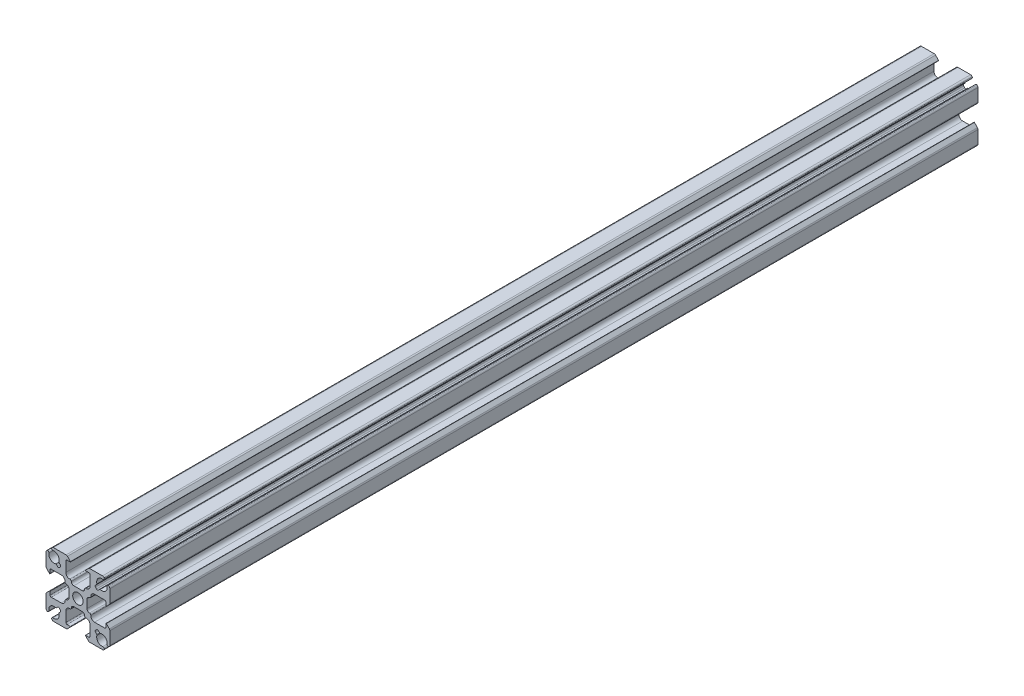
from build123d import *

# Parameters (mm, degrees)
SKETCH1_R                            = 2.08
BOSS_EXTRUDE1_DEPTH                  = 172.5549
SKETCH2_W                            = 2.5
SKETCH2_H                            = 16.3
TAP_DRILL_FOR_M6X1_0_TAP2_AT_2_COUNT = 2
TAP_DRILL_FOR_M6X1_0_TAP2_AT_2_PITCH = 135.89
SKETCH4_W                            = 2.5
SKETCH4_H                            = 16.3
TAP_DRILL_FOR_M6X1_0_TAP1_AT_2_COUNT = 2
TAP_DRILL_FOR_M6X1_0_TAP1_AT_2_PITCH = 120
TAP_DRILL_FOR_M6X1_0_TAP1_AT_3_COUNT = 2
TAP_DRILL_FOR_M6X1_0_TAP1_AT_3_PITCH = 240


with BuildPart() as part:
    # Sketch1 → Boss-Extrude1 (new body, symmetric)
    with BuildSketch(Plane(origin=(0, 0, 0), x_dir=(-1, 0, 0), z_dir=(0, 0, -1))):
        with BuildLine():
            Line((-7.48853247, 8.61990332), (-6.985643798, 8.117014648))
            ThreePointArc((-6.985643798, 8.117014648), (-6.839197188, 7.763461257), (-6.985643798, 7.409907866))
            Line((-6.985643798, 7.409907866), (-7.409907866, 6.985643798))
            ThreePointArc((-7.409907866, 6.985643798), (-7.763461257, 6.839197188), (-8.117014648, 6.985643798))
            Line((-8.117014648, 6.985643798), (-8.61990332, 7.48853247))
            ThreePointArc((-8.61990332, 7.48853247), (-8.738774884, 7.554957329), (-8.874825936, 7.549228331))
            ThreePointArc((-8.874825936, 7.549228331), (-10.889377278, 7.955008076), (-11.572136222, 9.893284252))
            ThreePointArc((-11.572136222, 9.893284252), (-11.766795458, 10.383720777), (-12.292708824, 10.42656157))
            ThreePointArc((-12.292708824, 10.42656157), (-12.590129525, 10.150252615), (-12.7, 9.759440396))
            Line((-12.7, 9.759440396), (-12.7, 4.710660172))
            ThreePointArc((-12.7, 4.710660172), (-12.642909649, 4.423647598), (-12.480330086, 4.180330086))
            Line((-12.480330086, 4.180330086), (-11.270710678, 2.970710678))
            ThreePointArc((-11.270710678, 2.970710678), (-11.161731657, 2.949033403), (-11.1, 3.041421356))
            Line((-11.1, 3.041421356), (-11.1, 4.325))
            ThreePointArc((-11.1, 4.325), (-10.953553391, 4.678553391), (-10.6, 4.825))
            Line((-10.6, 4.825), (-6.6, 4.825))
            ThreePointArc((-6.6, 4.825), (-5.539339828, 4.385660172), (-5.1, 3.325))
            Line((-5.1, 3.325), (-5.1, 3.15))
            ThreePointArc((-5.1, 3.15), (-4.953553391, 2.796446609), (-4.6, 2.65))
            ThreePointArc((-4.6, 2.65), (-3.892893219, 2.357106781), (-3.6, 1.65))
            Line((-3.6, 1.65), (-3.6, -1.65))
            ThreePointArc((-3.6, -1.65), (-3.892893219, -2.357106781), (-4.6, -2.65))
            ThreePointArc((-4.6, -2.65), (-4.953553391, -2.796446609), (-5.1, -3.15))
            Line((-5.1, -3.15), (-5.1, -3.325))
            ThreePointArc((-5.1, -3.325), (-5.539339828, -4.385660172), (-6.6, -4.825))
            Line((-6.6, -4.825), (-10.6, -4.825))
            ThreePointArc((-10.6, -4.825), (-10.953553391, -4.678553391), (-11.1, -4.325))
            Line((-11.1, -4.325), (-11.1, -3.041421356))
            ThreePointArc((-11.1, -3.041421356), (-11.161731657, -2.949033403), (-11.270710678, -2.970710678))
            Line((-11.270710678, -2.970710678), (-12.480330086, -4.180330086))
            ThreePointArc((-12.480330086, -4.180330086), (-12.642909649, -4.423647598), (-12.7, -4.710660172))
            Line((-12.7, -4.710660172), (-12.7, -9.759440396))
            ThreePointArc((-12.7, -9.759440396), (-12.590129525, -10.150252615), (-12.292708824, -10.42656157))
            ThreePointArc((-12.292708824, -10.42656157), (-11.766795458, -10.383720777), (-11.572136222, -9.893284252))
            ThreePointArc((-11.572136222, -9.893284252), (-10.889377278, -7.955008076), (-8.874825936, -7.549228331))
            ThreePointArc((-8.874825936, -7.549228331), (-8.738774884, -7.554957329), (-8.61990332, -7.48853247))
            Line((-8.61990332, -7.48853247), (-8.117014648, -6.985643798))
            ThreePointArc((-8.117014648, -6.985643798), (-7.763461257, -6.839197188), (-7.409907866, -6.985643798))
            Line((-7.409907866, -6.985643798), (-6.985643798, -7.409907866))
            ThreePointArc((-6.985643798, -7.409907866), (-6.839197188, -7.763461257), (-6.985643798, -8.117014648))
            Line((-6.985643798, -8.117014648), (-7.48853247, -8.61990332))
            ThreePointArc((-7.48853247, -8.61990332), (-7.554957329, -8.738774884), (-7.549228331, -8.874825936))
            ThreePointArc((-7.549228331, -8.874825936), (-7.955008076, -10.889377278), (-9.893284252, -11.572136222))
            ThreePointArc((-9.893284252, -11.572136222), (-10.383720777, -11.766795458), (-10.42656157, -12.292708824))
            ThreePointArc((-10.42656157, -12.292708824), (-10.150252615, -12.590129525), (-9.759440396, -12.7))
            Line((-9.759440396, -12.7), (-4.710660172, -12.7))
            ThreePointArc((-4.710660172, -12.7), (-4.423647598, -12.642909649), (-4.180330086, -12.480330086))
            Line((-4.180330086, -12.480330086), (-2.970710678, -11.270710678))
            ThreePointArc((-2.970710678, -11.270710678), (-2.949033403, -11.161731657), (-3.041421356, -11.1))
            Line((-3.041421356, -11.1), (-4.325, -11.1))
            ThreePointArc((-4.325, -11.1), (-4.678553391, -10.953553391), (-4.825, -10.6))
            Line((-4.825, -10.6), (-4.825, -6.6))
            ThreePointArc((-4.825, -6.6), (-4.385660172, -5.539339828), (-3.325, -5.1))
            Line((-3.325, -5.1), (-3.15, -5.1))
            ThreePointArc((-3.15, -5.1), (-2.796446609, -4.953553391), (-2.65, -4.6))
            ThreePointArc((-2.65, -4.6), (-2.357106781, -3.892893219), (-1.65, -3.6))
            Line((-1.65, -3.6), (1.65, -3.6))
            ThreePointArc((1.65, -3.6), (2.357106781, -3.892893219), (2.65, -4.6))
            ThreePointArc((2.65, -4.6), (2.796446609, -4.953553391), (3.15, -5.1))
            Line((3.15, -5.1), (3.325, -5.1))
            ThreePointArc((3.325, -5.1), (4.385660172, -5.539339828), (4.825, -6.6))
            Line((4.825, -6.6), (4.825, -10.6))
            ThreePointArc((4.825, -10.6), (4.678553391, -10.953553391), (4.325, -11.1))
            Line((4.325, -11.1), (3.041421356, -11.1))
            ThreePointArc((3.041421356, -11.1), (2.949033403, -11.161731657), (2.970710678, -11.270710678))
            Line((2.970710678, -11.270710678), (4.180330086, -12.480330086))
            ThreePointArc((4.180330086, -12.480330086), (4.423647598, -12.642909649), (4.710660172, -12.7))
            Line((4.710660172, -12.7), (9.759440396, -12.7))
            ThreePointArc((9.759440396, -12.7), (10.150252615, -12.590129525), (10.42656157, -12.292708824))
            ThreePointArc((10.42656157, -12.292708824), (10.383720777, -11.766795458), (9.893284252, -11.572136222))
            ThreePointArc((9.893284252, -11.572136222), (7.955008076, -10.889377278), (7.549228331, -8.874825936))
            ThreePointArc((7.549228331, -8.874825936), (7.554957329, -8.738774884), (7.48853247, -8.61990332))
            Line((7.48853247, -8.61990332), (6.985643798, -8.117014648))
            ThreePointArc((6.985643798, -8.117014648), (6.839197188, -7.763461257), (6.985643798, -7.409907866))
            Line((6.985643798, -7.409907866), (7.409907866, -6.985643798))
            ThreePointArc((7.409907866, -6.985643798), (7.763461257, -6.839197188), (8.117014648, -6.985643798))
            Line((8.117014648, -6.985643798), (8.61990332, -7.48853247))
            ThreePointArc((8.61990332, -7.48853247), (8.738774884, -7.554957329), (8.874825936, -7.549228331))
            ThreePointArc((8.874825936, -7.549228331), (10.889377278, -7.955008076), (11.572136222, -9.893284252))
            ThreePointArc((11.572136222, -9.893284252), (11.766795458, -10.383720777), (12.292708824, -10.42656157))
            ThreePointArc((12.292708824, -10.42656157), (12.590129525, -10.150252615), (12.7, -9.759440396))
            Line((12.7, -9.759440396), (12.7, -4.710660172))
            ThreePointArc((12.7, -4.710660172), (12.642909649, -4.423647598), (12.480330086, -4.180330086))
            Line((12.480330086, -4.180330086), (11.270710678, -2.970710678))
            ThreePointArc((11.270710678, -2.970710678), (11.161731657, -2.949033403), (11.1, -3.041421356))
            Line((11.1, -3.041421356), (11.1, -4.325))
            ThreePointArc((11.1, -4.325), (10.953553391, -4.678553391), (10.6, -4.825))
            Line((10.6, -4.825), (6.6, -4.825))
            ThreePointArc((6.6, -4.825), (5.539339828, -4.385660172), (5.1, -3.325))
            Line((5.1, -3.325), (5.1, -3.15))
            ThreePointArc((5.1, -3.15), (4.953553391, -2.796446609), (4.6, -2.65))
            ThreePointArc((4.6, -2.65), (3.892893219, -2.357106781), (3.6, -1.65))
            Line((3.6, -1.65), (3.6, 1.65))
            ThreePointArc((3.6, 1.65), (3.892893219, 2.357106781), (4.6, 2.65))
            ThreePointArc((4.6, 2.65), (4.953553391, 2.796446609), (5.1, 3.15))
            Line((5.1, 3.15), (5.1, 3.325))
            ThreePointArc((5.1, 3.325), (5.539339828, 4.385660172), (6.6, 4.825))
            Line((6.6, 4.825), (10.6, 4.825))
            ThreePointArc((10.6, 4.825), (10.953553391, 4.678553391), (11.1, 4.325))
            Line((11.1, 4.325), (11.1, 3.041421356))
            ThreePointArc((11.1, 3.041421356), (11.161731657, 2.949033403), (11.270710678, 2.970710678))
            Line((11.270710678, 2.970710678), (12.480330086, 4.180330086))
            ThreePointArc((12.480330086, 4.180330086), (12.642909649, 4.423647598), (12.7, 4.710660172))
            Line((12.7, 4.710660172), (12.7, 9.759440396))
            ThreePointArc((12.7, 9.759440396), (12.590129525, 10.150252615), (12.292708824, 10.42656157))
            ThreePointArc((12.292708824, 10.42656157), (11.766795458, 10.383720777), (11.572136222, 9.893284252))
            ThreePointArc((11.572136222, 9.893284252), (10.889377278, 7.955008076), (8.874825936, 7.549228331))
            ThreePointArc((8.874825936, 7.549228331), (8.738774884, 7.554957329), (8.61990332, 7.48853247))
            Line((8.61990332, 7.48853247), (8.117014648, 6.985643798))
            ThreePointArc((8.117014648, 6.985643798), (7.763461257, 6.839197188), (7.409907866, 6.985643798))
            Line((7.409907866, 6.985643798), (6.985643798, 7.409907866))
            ThreePointArc((6.985643798, 7.409907866), (6.839197188, 7.763461257), (6.985643798, 8.117014648))
            Line((6.985643798, 8.117014648), (7.48853247, 8.61990332))
            ThreePointArc((7.48853247, 8.61990332), (7.554957329, 8.738774884), (7.549228331, 8.874825936))
            ThreePointArc((7.549228331, 8.874825936), (7.955008076, 10.889377278), (9.893284252, 11.572136222))
            ThreePointArc((9.893284252, 11.572136222), (10.383720777, 11.766795458), (10.42656157, 12.292708824))
            ThreePointArc((10.42656157, 12.292708824), (10.150252615, 12.590129525), (9.759440396, 12.7))
            Line((9.759440396, 12.7), (4.710660172, 12.7))
            ThreePointArc((4.710660172, 12.7), (4.423647598, 12.642909649), (4.180330086, 12.480330086))
            Line((4.180330086, 12.480330086), (2.970710678, 11.270710678))
            ThreePointArc((2.970710678, 11.270710678), (2.949033403, 11.161731657), (3.041421356, 11.1))
            Line((3.041421356, 11.1), (4.325, 11.1))
            ThreePointArc((4.325, 11.1), (4.678553391, 10.953553391), (4.825, 10.6))
            Line((4.825, 10.6), (4.825, 6.6))
            ThreePointArc((4.825, 6.6), (4.385660172, 5.539339828), (3.325, 5.1))
            Line((3.325, 5.1), (3.15, 5.1))
            ThreePointArc((3.15, 5.1), (2.796446609, 4.953553391), (2.65, 4.6))
            ThreePointArc((2.65, 4.6), (2.357106781, 3.892893219), (1.65, 3.6))
            Line((1.65, 3.6), (-1.65, 3.6))
            ThreePointArc((-1.65, 3.6), (-2.357106781, 3.892893219), (-2.65, 4.6))
            ThreePointArc((-2.65, 4.6), (-2.796446609, 4.953553391), (-3.15, 5.1))
            Line((-3.15, 5.1), (-3.325, 5.1))
            ThreePointArc((-3.325, 5.1), (-4.385660172, 5.539339828), (-4.825, 6.6))
            Line((-4.825, 6.6), (-4.825, 10.6))
            ThreePointArc((-4.825, 10.6), (-4.678553391, 10.953553391), (-4.325, 11.1))
            Line((-4.325, 11.1), (-3.041421356, 11.1))
            ThreePointArc((-3.041421356, 11.1), (-2.949033403, 11.161731657), (-2.970710678, 11.270710678))
            Line((-2.970710678, 11.270710678), (-4.180330086, 12.480330086))
            ThreePointArc((-4.180330086, 12.480330086), (-4.423647598, 12.642909649), (-4.710660172, 12.7))
            Line((-4.710660172, 12.7), (-9.759440396, 12.7))
            ThreePointArc((-9.759440396, 12.7), (-10.150252615, 12.590129525), (-10.42656157, 12.292708824))
            ThreePointArc((-10.42656157, 12.292708824), (-10.383720777, 11.766795458), (-9.893284252, 11.572136222))
            ThreePointArc((-9.893284252, 11.572136222), (-7.955008076, 10.889377278), (-7.549228331, 8.874825936))
            ThreePointArc((-7.549228331, 8.874825936), (-7.554957329, 8.738774884), (-7.48853247, 8.61990332))
        make_face()
        Circle(SKETCH1_R, mode=Mode.SUBTRACT)
    extrude(amount=BOSS_EXTRUDE1_DEPTH, both=True)

    # Sketch2 → Tap Drill for M6x1.0 Tap2 (revolve, cut)
    with BuildSketch(Plane(origin=(3.6, -4.450000001, 120.884899996), x_dir=(0, 0, -1), z_dir=(0, 1, 0))):
        with Locations((1.25, 8.15)):
            Rectangle(SKETCH2_W, SKETCH2_H)
    tap_drill_for_m6x1_0_tap2 = revolve(axis=Axis((9.95, -4.450000001, 120.884899996), (-1, 0, 0)), mode=Mode.SUBTRACT)

    # Tap Drill for M6x1.0 Tap2 at 2: Tap Drill for M6x1.0 Tap2 ×2
    with Locations(*[(0, 0, -i * TAP_DRILL_FOR_M6X1_0_TAP2_AT_2_PITCH) for i in range(1, TAP_DRILL_FOR_M6X1_0_TAP2_AT_2_COUNT)]):
        add(tap_drill_for_m6x1_0_tap2, mode=Mode.SUBTRACT)

    # Sketch4 → Tap Drill for M6x1.0 Tap1 (revolve, cut)
    with BuildSketch(Plane(origin=(-3.6, 0, 151.604899989), x_dir=(0, 0, 1), z_dir=(0, 1, 0))):
        with Locations((1.25, 8.15)):
            Rectangle(SKETCH4_W, SKETCH4_H)
    tap_drill_for_m6x1_0_tap1 = revolve(axis=Axis((-9.95, 0, 151.604899989), (1, 0, 0)), mode=Mode.SUBTRACT)

    # Tap Drill for M6x1.0 Tap1 at 2: Tap Drill for M6x1.0 Tap1 ×2
    with Locations(*[(0, 0, -i * TAP_DRILL_FOR_M6X1_0_TAP1_AT_2_PITCH) for i in range(1, TAP_DRILL_FOR_M6X1_0_TAP1_AT_2_COUNT)]):
        add(tap_drill_for_m6x1_0_tap1, mode=Mode.SUBTRACT)

    # Tap Drill for M6x1.0 Tap1 at 3: Tap Drill for M6x1.0 Tap1 ×2
    with Locations(*[(0, 0, -i * TAP_DRILL_FOR_M6X1_0_TAP1_AT_3_PITCH) for i in range(1, TAP_DRILL_FOR_M6X1_0_TAP1_AT_3_COUNT)]):
        add(tap_drill_for_m6x1_0_tap1, mode=Mode.SUBTRACT)


solid = part.part
